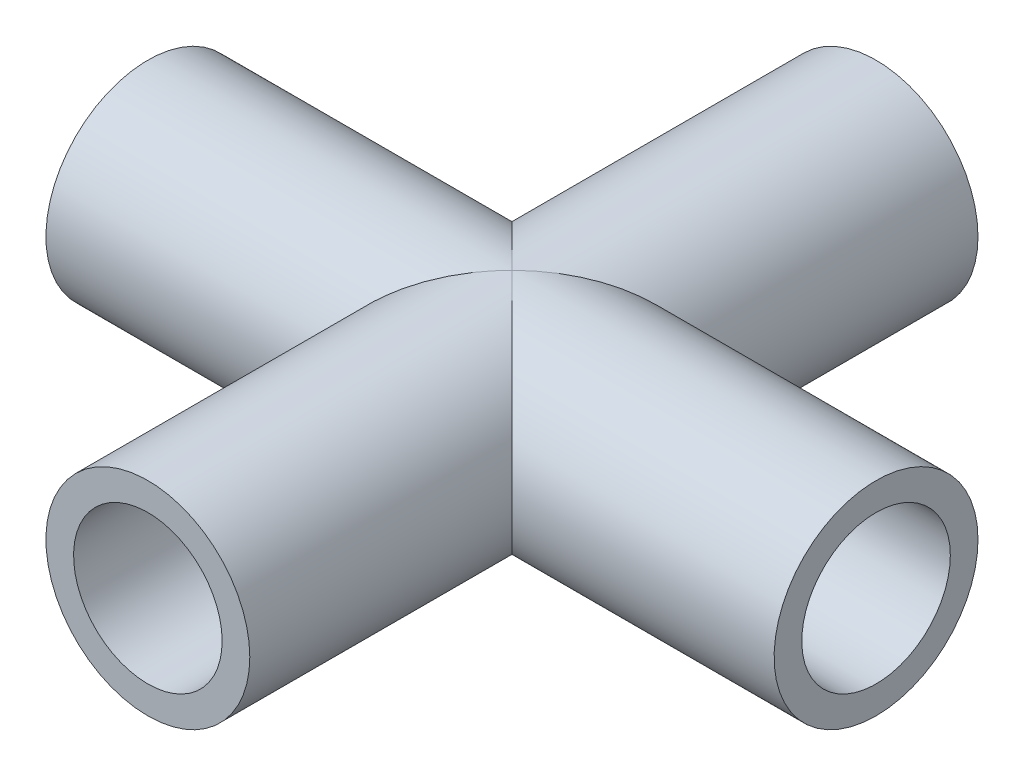
from build123d import *

# Parameters (mm, degrees)
SKETCH1_R           = 8.89
SKETCH1_R_2         = 6.477
BOSS_EXTRUDE1_DEPTH = 63.5
SKETCH2_R           = 8.89
SKETCH2_R_2         = 6.477
BOSS_EXTRUDE2_DEPTH = 31.75
SKETCH4_R           = 6.477
CUT_EXTRUDE1_DEPTH  = 64.5000001
SKETCH5_R           = 6.477
CUT_EXTRUDE2_DEPTH  = 64.5000001


with BuildPart() as part:
    # Sketch1 → Boss-Extrude1 (new body)
    with BuildSketch(Plane.XY):
        Circle(SKETCH1_R)
        Circle(SKETCH1_R_2, mode=Mode.SUBTRACT)
    extrude(amount=BOSS_EXTRUDE1_DEPTH)

    # Sketch2 → Boss-Extrude2 (add, symmetric)
    with BuildSketch(Plane(origin=(0, 0, 0), x_dir=(0, 0, -1), z_dir=(1, 0, 0))):
        with Locations((-31.75, 0)):
            Circle(SKETCH2_R)
        with Locations((-31.75, 0)):
            Circle(SKETCH2_R_2, mode=Mode.SUBTRACT)
    extrude(amount=BOSS_EXTRUDE2_DEPTH, both=True)

    # Sketch4 → Cut-Extrude1 (cut, through all)
    with BuildSketch(Plane(origin=(0, 0, 0), x_dir=(-1, 0, 0), z_dir=(0, 0, -1))):
        Circle(SKETCH4_R)
    extrude(amount=-CUT_EXTRUDE1_DEPTH, mode=Mode.SUBTRACT)

    # Sketch5 → Cut-Extrude2 (cut, through all)
    with BuildSketch(Plane(origin=(31.75, 0, 0), x_dir=(0, 0, -1), z_dir=(1, 0, 0))):
        with Locations((-31.75, 0)):
            Circle(SKETCH5_R)
    extrude(amount=-CUT_EXTRUDE2_DEPTH, mode=Mode.SUBTRACT)


solid = part.part
